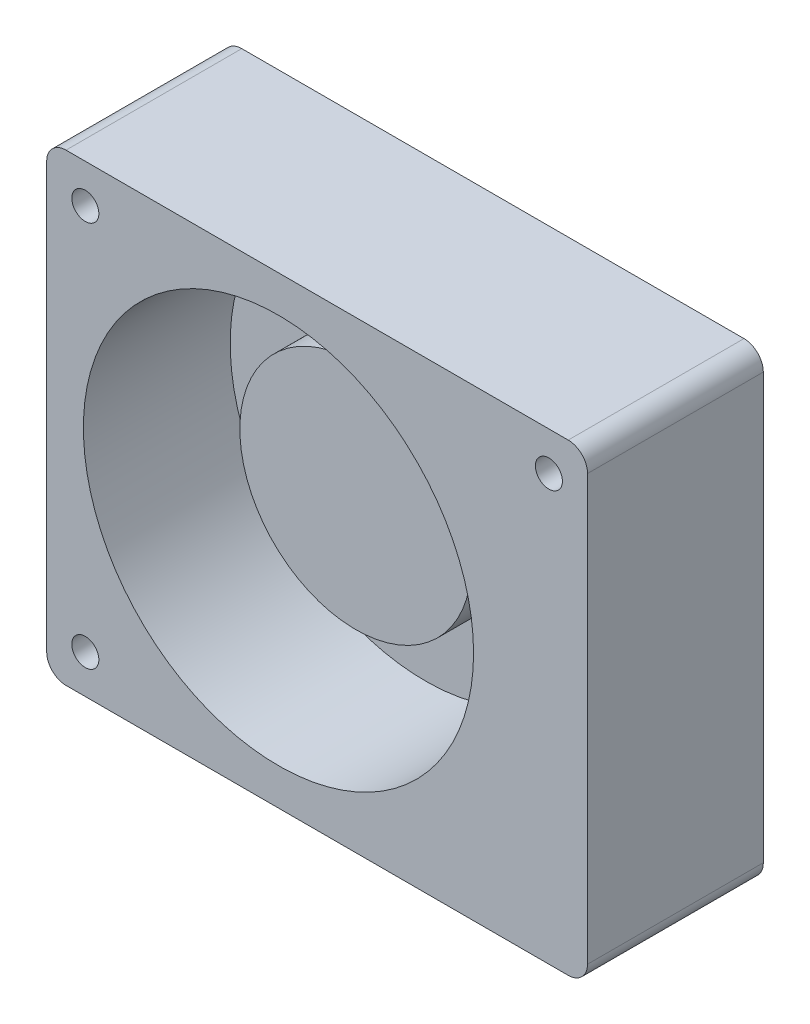
from build123d import *

# Parameters (mm, degrees)
BOSS_EXTRUDE1_DEPTH = 45.5
SKETCH3_R           = 3.5
CUT_EXTRUDE1_DEPTH  = 46.5
SKETCH5_R           = 50.5
SKETCH5_R_2         = 30
CUT_EXTRUDE2_DEPTH  = 38
SKETCH6_R           = 30
CUT_EXTRUDE3_DEPTH  = 20


with BuildPart() as part:
    # Sketch1 → Boss-Extrude1 (new body)
    with BuildSketch(Plane.XY):
        with BuildLine():
            Line((0, 5), (0, 115))
            ThreePointArc((0, 115), (1.464466094, 118.535533906), (5, 120))
            Line((5, 120), (135, 120))
            ThreePointArc((135, 120), (138.535533906, 118.535533906), (140, 115))
            Line((140, 115), (140, 5))
            ThreePointArc((140, 5), (138.535533906, 1.464466094), (135, 0))
            Line((135, 0), (5, 0))
            ThreePointArc((5, 0), (1.464466094, 1.464466094), (0, 5))
        make_face()
    extrude(amount=BOSS_EXTRUDE1_DEPTH)

    # Sketch3 → Cut-Extrude1 (cut, through all)
    with BuildSketch(Plane.XY.offset(45.5)):
        with Locations((10, 110)):
            Circle(SKETCH3_R)
        with Locations((130, 110)):
            Circle(SKETCH3_R)
        with Locations((10, 10)):
            Circle(SKETCH3_R)
    extrude(amount=-CUT_EXTRUDE1_DEPTH, mode=Mode.SUBTRACT)

    # Sketch5 → Cut-Extrude2 (cut)
    with BuildSketch(Plane.XY.offset(45.5)):
        with Locations((60, 60)):
            Circle(SKETCH5_R)
        with Locations((60, 60)):
            Circle(SKETCH5_R_2, mode=Mode.SUBTRACT)
    extrude(amount=-CUT_EXTRUDE2_DEPTH, mode=Mode.SUBTRACT)

    # Sketch6 → Cut-Extrude3 (cut)
    with BuildSketch(Plane.XY.offset(45.5)):
        with Locations((60, 60)):
            Circle(SKETCH6_R)
    extrude(amount=-CUT_EXTRUDE3_DEPTH, mode=Mode.SUBTRACT)


solid = part.part
